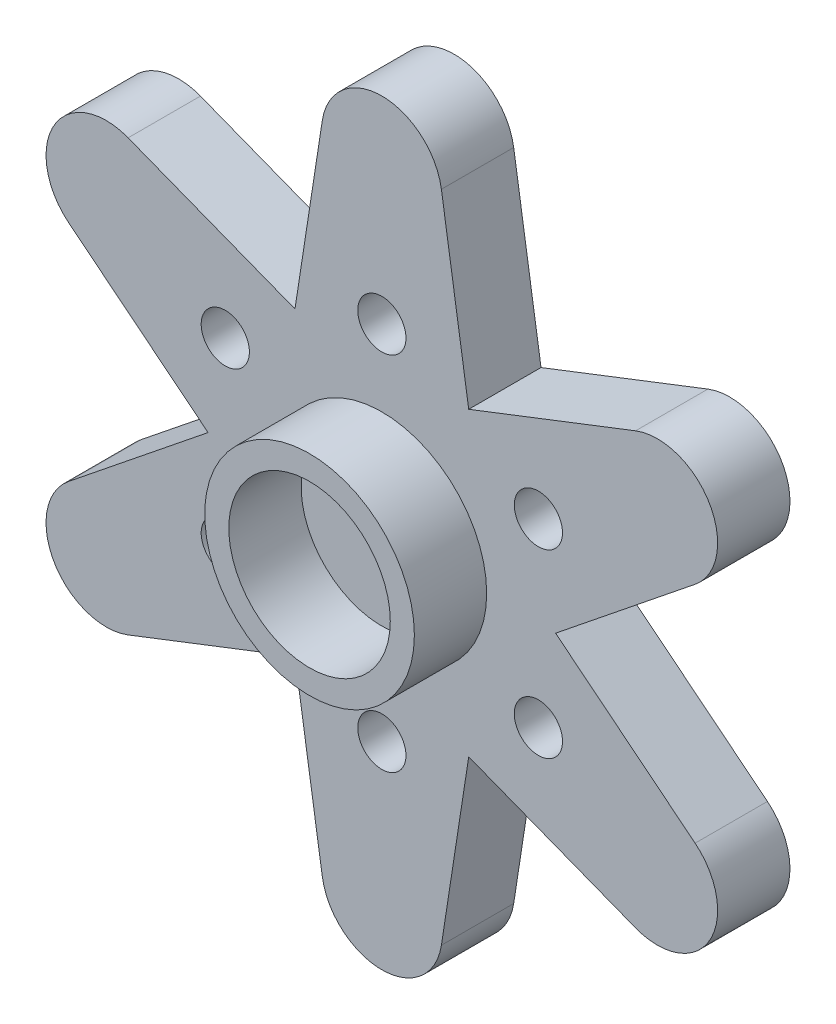
from build123d import *

# Parameters (mm, degrees)
SKETCH_1_R        = 1
EXTRUDE_1_DEPTH   = 3
SKETCH_2_R        = 4.35
SKETCH_2_R_2      = 3.35
EXTRUDE_1_2_DEPTH = 3


with BuildPart() as part:
    # 草图1 → Extrude 1 (new body)
    with BuildSketch(Plane.XY):
        with BuildLine():
            Line((-2.470698832, 13.581637634), (-3.604292918, 6.242818459))
            Line((-3.604292918, 6.242818459), (-10.5266938, 8.93050677))
            ThreePointArc((-10.5266938, 8.93050677), (-13.596598839, 7.85), (-12.997392632, 4.651130864))
            Line((-12.997392632, 4.651130864), (-7.208585836, 0))
            Line((-7.208585836, 0), (-12.997392632, -4.651130864))
            ThreePointArc((-12.997392632, -4.651130864), (-13.596598839, -7.85), (-10.5266938, -8.93050677))
            Line((-10.5266938, -8.93050677), (-3.604292918, -6.242818459))
            Line((-3.604292918, -6.242818459), (-2.470698832, -13.581637634))
            ThreePointArc((-2.470698832, -13.581637634), (0, -15.7), (2.470698832, -13.581637634))
            Line((2.470698832, -13.581637634), (3.604292918, -6.242818459))
            Line((3.604292918, -6.242818459), (10.5266938, -8.93050677))
            ThreePointArc((10.5266938, -8.93050677), (13.596598839, -7.85), (12.997392632, -4.651130864))
            Line((12.997392632, -4.651130864), (7.208585836, 0))
            Line((7.208585836, 0), (12.997392632, 4.651130864))
            ThreePointArc((12.997392632, 4.651130864), (13.596598839, 7.85), (10.5266938, 8.93050677))
            Line((10.5266938, 8.93050677), (3.604292918, 6.242818459))
            Line((3.604292918, 6.242818459), (2.470698832, 13.581637634))
            ThreePointArc((2.470698832, 13.581637634), (0, 15.7), (-2.470698832, 13.581637634))
        make_face()
        with Locations((6.495190528, 3.75)):
            Circle(SKETCH_1_R, mode=Mode.SUBTRACT)
        with Locations((0, 7.5)):
            Circle(SKETCH_1_R, mode=Mode.SUBTRACT)
        with Locations((6.495190528, -3.75)):
            Circle(SKETCH_1_R, mode=Mode.SUBTRACT)
        with Locations((0, -7.5)):
            Circle(SKETCH_1_R, mode=Mode.SUBTRACT)
        with Locations((-6.495190528, -3.75)):
            Circle(SKETCH_1_R, mode=Mode.SUBTRACT)
        with Locations((-6.495190528, 3.75)):
            Circle(SKETCH_1_R, mode=Mode.SUBTRACT)
    extrude(amount=EXTRUDE_1_DEPTH)

    # 草图2 → Extrude 1 2 (add)
    with BuildSketch(Plane.XY.offset(3)):
        Circle(SKETCH_2_R)
        Circle(SKETCH_2_R_2, mode=Mode.SUBTRACT)
    extrude(amount=EXTRUDE_1_2_DEPTH)


solid = part.part
